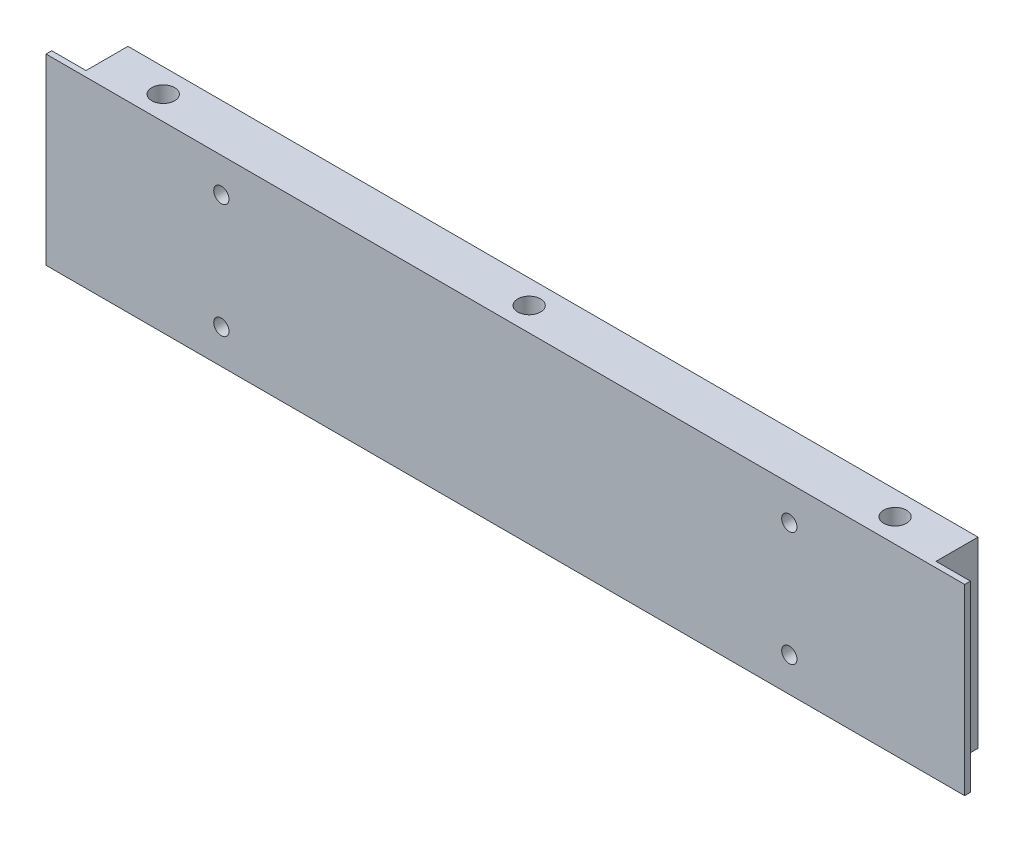
from build123d import *

# Parameters (mm, degrees)
ESQUISSE1_W      = 241
ESQUISSE1_H      = 48
ESQUISSE1_R      = 2
EXTRUSION1_DEPTH = 12.5
ESQUISSE2_W      = 9
ESQUISSE2_H      = 11
EXTRUSION2_DEPTH = 49
EXTRUSION3_REACH = 50
ESQUISSE3_R      = 3


with BuildPart() as part:
    # Esquisse1 → Extrusion1 (new body)
    with BuildSketch(Plane.XY):
        with Locations((120.5, -24)):
            Rectangle(ESQUISSE1_W, ESQUISSE1_H)
        with Locations((195, -39)):
            Circle(ESQUISSE1_R, mode=Mode.SUBTRACT)
        with Locations((46, -9)):
            Circle(ESQUISSE1_R, mode=Mode.SUBTRACT)
        with Locations((46, -39)):
            Circle(ESQUISSE1_R, mode=Mode.SUBTRACT)
        with Locations((195, -9)):
            Circle(ESQUISSE1_R, mode=Mode.SUBTRACT)
    extrude(amount=EXTRUSION1_DEPTH)

    # Esquisse2 → Extrusion2 (cut, through all)
    with BuildSketch(Plane(origin=(0, 0, 0), x_dir=(1, 0, 0), z_dir=(0, 1, 0))):
        with Locations((4.5, -5.5)):
            Rectangle(ESQUISSE2_W, ESQUISSE2_H)
        with Locations((236.5, -5.5)):
            Rectangle(ESQUISSE2_W, ESQUISSE2_H)
    extrude(amount=-EXTRUSION2_DEPTH, mode=Mode.SUBTRACT)

    # Esquisse3 → Extrusion3 (cut, up to next)
    with BuildSketch(Plane(origin=(0, 0, 0), x_dir=(1, 0, 0), z_dir=(0, 1, 0)), mode=Mode.PRIVATE) as extrusion3_sk1:
        with Locations((120.5, -6.25)):
            Circle(ESQUISSE3_R)
    extrusion3_tool1 = extrude(extrusion3_sk1.sketch, amount=-EXTRUSION3_REACH, mode=Mode.PRIVATE) & part.part
    add(extrusion3_tool1.solids().sort_by_distance((120.5, 0, 6.25))[0], mode=Mode.SUBTRACT)
    # Esquisse3 → Extrusion3 (cut, up to next)
    with BuildSketch(Plane(origin=(0, 0, 0), x_dir=(1, 0, 0), z_dir=(0, 1, 0)), mode=Mode.PRIVATE) as extrusion3_sk2:
        with Locations((24.5, -6.25)):
            Circle(ESQUISSE3_R)
    extrusion3_tool2 = extrude(extrusion3_sk2.sketch, amount=-EXTRUSION3_REACH, mode=Mode.PRIVATE) & part.part
    add(extrusion3_tool2.solids().sort_by_distance((24.5, 0, 6.25))[0], mode=Mode.SUBTRACT)
    # Esquisse3 → Extrusion3 (cut, up to next)
    with BuildSketch(Plane(origin=(0, 0, 0), x_dir=(1, 0, 0), z_dir=(0, 1, 0)), mode=Mode.PRIVATE) as extrusion3_sk3:
        with Locations((216.5, -6.25)):
            Circle(ESQUISSE3_R)
    extrusion3_tool3 = extrude(extrusion3_sk3.sketch, amount=-EXTRUSION3_REACH, mode=Mode.PRIVATE) & part.part
    add(extrusion3_tool3.solids().sort_by_distance((216.5, 0, 6.25))[0], mode=Mode.SUBTRACT)


solid = part.part
